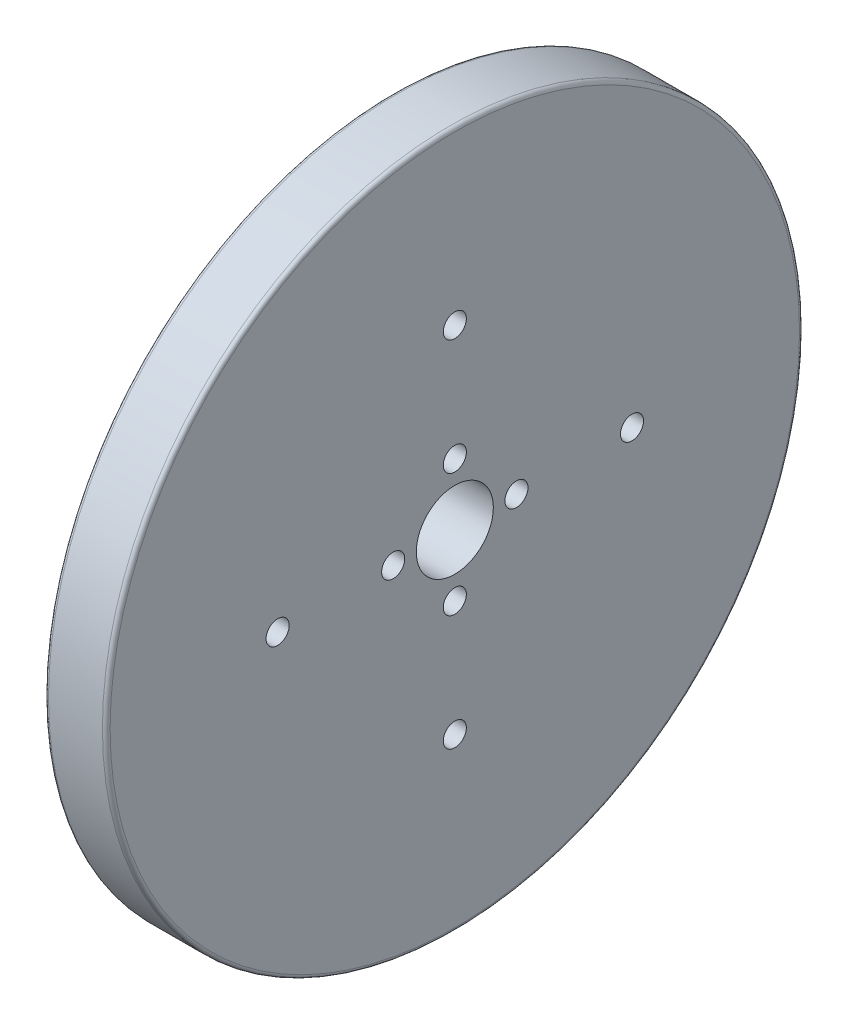
from build123d import *

# Parameters (mm, degrees)
SPROCKET_R                   = 45.25
ESTRUSIONE_ESTRUSIONE2_DEPTH = 8
SCHIZZO1_R                   = 5
SCHIZZO1_R_2                 = 1.5
TAGLIO_ESTRUSIONE2_DEPTH     = 9
RACCORDO1_R                  = 0.5


with BuildPart() as part:
    # Sprocket → Estrusione-Estrusione2 (new body)
    with BuildSketch(Plane(origin=(0, 0, 0), x_dir=(0, 0, -1), z_dir=(1, 0, 0))):
        Circle(SPROCKET_R)
    extrude(amount=ESTRUSIONE_ESTRUSIONE2_DEPTH)

    # Schizzo1 → Taglio-Estrusione2 (cut, through all)
    with BuildSketch(Plane(origin=(0, 0, 0), x_dir=(0, 0, -1), z_dir=(1, 0, 0))):
        Circle(SCHIZZO1_R)
        with Locations((0, 23)):
            Circle(SCHIZZO1_R_2)
        with Locations((8, 0)):
            Circle(SCHIZZO1_R_2)
        with Locations((0, 8)):
            Circle(SCHIZZO1_R_2)
        with Locations((23, 0)):
            Circle(SCHIZZO1_R_2)
        with Locations((0, -8)):
            Circle(SCHIZZO1_R_2)
        with Locations((0, -23)):
            Circle(SCHIZZO1_R_2)
        with Locations((-8, 0)):
            Circle(SCHIZZO1_R_2)
        with Locations((-23, 0)):
            Circle(SCHIZZO1_R_2)
    extrude(amount=TAGLIO_ESTRUSIONE2_DEPTH, mode=Mode.SUBTRACT)

    # Raccordo1
    raccordo1_edges = [part.edges().sort_by_distance(p)[0] for p in [
        (0, 0, 45.25),
        (8, 0, 45.25),
    ]]
    fillet(raccordo1_edges, radius=RACCORDO1_R)


solid = part.part
